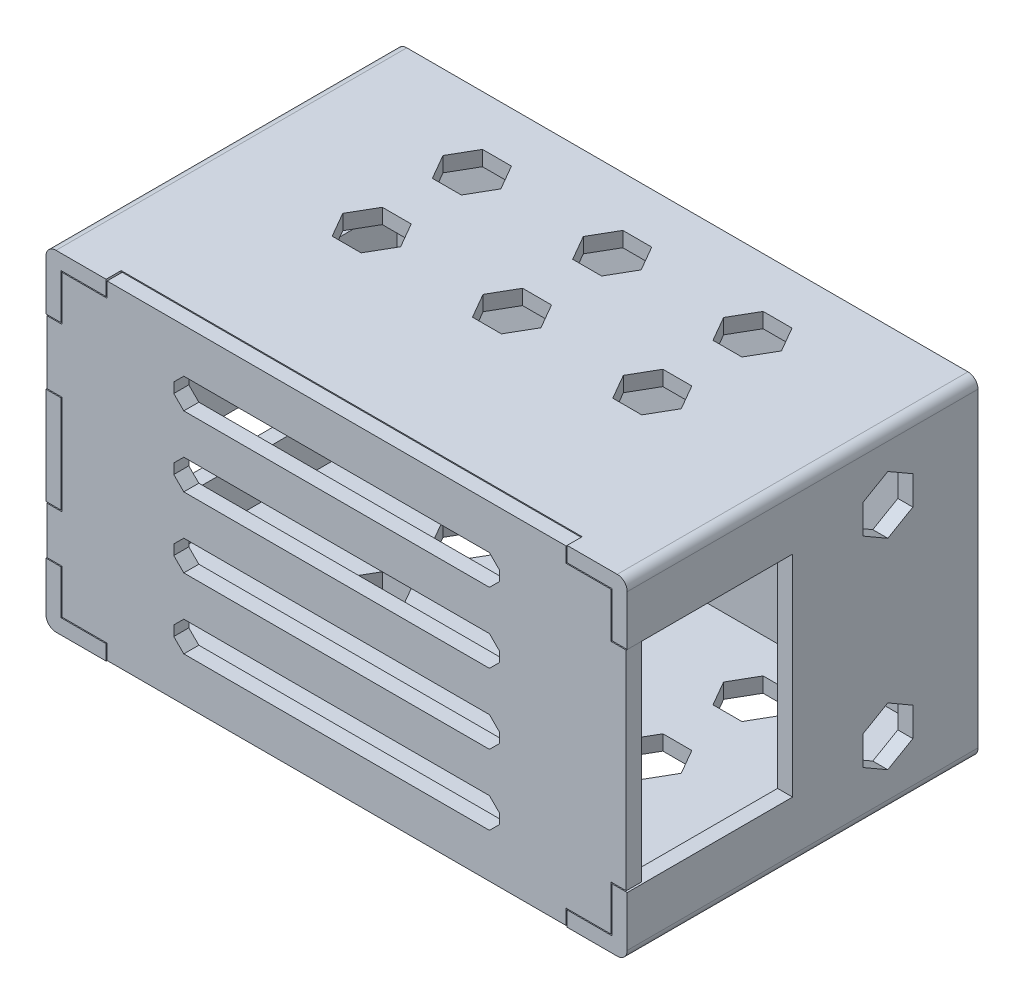
from build123d import *

# Parameters (mm, degrees)
SKETCH1_W           = 116
SKETCH1_H           = 66
SKETCH1_W_2         = 110
SKETCH1_H_2         = 60
BOSS_EXTRUDE1_DEPTH = 70
SKETCH1_2_W         = 110
SKETCH1_2_H         = 60
BOSS_EXTRUDE2_DEPTH = 3
CUT_EXTRUDE1_REACH  = 118
SKETCH2_W           = 65
SKETCH2_H           = 9.8
SKETCH2_H_2         = 13
CUT_EXTRUDE2_DEPTH  = 67
CUT_EXTRUDE3_REACH  = 118
SKETCH5_W           = 92
SKETCH5_H           = 3
SKETCH5_W_2         = 3
SKETCH5_H_2         = 42
CUT_EXTRUDE4_DEPTH  = 3
SKETCH6_W           = 2.8
SKETCH6_H           = 41.6
BOSS_EXTRUDE3_DEPTH = 3
SKETCH7_W           = 65
SKETCH7_H           = 6
CUT_EXTRUDE5_DEPTH  = 3
SKETCH8_W           = 3
SKETCH8_H           = 42
CUT_EXTRUDE6_DEPTH  = 30
CHAMFER1_SIZE       = 2
FILLET1_R           = 2


with BuildPart() as part:
    # Sketch1 → Boss-Extrude1 (new body)
    with BuildSketch(Plane.XY):
        Rectangle(SKETCH1_W, SKETCH1_H)
        Rectangle(SKETCH1_W_2, SKETCH1_H_2, mode=Mode.SUBTRACT)
    extrude(amount=BOSS_EXTRUDE1_DEPTH)

    # Sketch1_2 → Boss-Extrude2 (add)
    with BuildSketch(Plane.XY):
        Rectangle(SKETCH1_2_W, SKETCH1_2_H)
    extrude(amount=BOSS_EXTRUDE2_DEPTH)

    # Sketch2 → Cut-Extrude1 (cut, up to next)
    with BuildSketch(Plane.ZY.offset(58), mode=Mode.PRIVATE) as cut_extrude1_sk1:
        with Locations((37.5, -16.3)):
            Rectangle(SKETCH2_W, SKETCH2_H)
    cut_extrude1_tool1 = extrude(cut_extrude1_sk1.sketch, amount=-CUT_EXTRUDE1_REACH, mode=Mode.PRIVATE) & part.part
    add(cut_extrude1_tool1.solids().sort_by_distance((-58, -16.3, 37.5))[0], mode=Mode.SUBTRACT)
    # Sketch2 → Cut-Extrude1 (cut, up to next)
    with BuildSketch(Plane.ZY.offset(58), mode=Mode.PRIVATE) as cut_extrude1_sk2:
        with Locations((37.5, 14.5)):
            Rectangle(SKETCH2_W, SKETCH2_H_2)
    cut_extrude1_tool2 = extrude(cut_extrude1_sk2.sketch, amount=-CUT_EXTRUDE1_REACH, mode=Mode.PRIVATE) & part.part
    add(cut_extrude1_tool2.solids().sort_by_distance((-58, 14.5, 37.5))[0], mode=Mode.SUBTRACT)

    # Sketch3 → Cut-Extrude2 (cut, through all)
    with BuildSketch(Plane.XZ.offset(33)):
        Polygon((-25.113248654, 40), (-30.886751346, 40), (-33.773502692, 35), (-30.886751346, 30), (-25.113248654, 30), (-22.226497308, 35), align=None)
        Polygon((2.886751346, 40), (-2.886751346, 40), (-5.773502692, 35), (-2.886751346, 30), (2.886751346, 30), (5.773502692, 35), align=None)
        Polygon((30.886751346, 40), (25.113248654, 40), (22.226497308, 35), (25.113248654, 30), (30.886751346, 30), (33.773502692, 35), align=None)
        Polygon((30.886751346, 20), (25.113248654, 20), (22.226497308, 15), (25.113248654, 10), (30.886751346, 10), (33.773502692, 15), align=None)
        Polygon((2.886751346, 20), (-2.886751346, 20), (-5.773502692, 15), (-2.886751346, 10), (2.886751346, 10), (5.773502692, 15), align=None)
        Polygon((-25.113248654, 20), (-30.886751346, 20), (-33.773502692, 15), (-30.886751346, 10), (-25.113248654, 10), (-22.226497308, 15), align=None)
    extrude(amount=-CUT_EXTRUDE2_DEPTH, mode=Mode.SUBTRACT)

    # Sketch4 → Cut-Extrude3 (cut, up to next)
    with BuildSketch(Plane(origin=(58, 0, 0), x_dir=(0, 0, -1), z_dir=(1, 0, 0)), mode=Mode.PRIVATE) as cut_extrude3_sk1:
        Polygon((-18, 25.773502692), (-23, 22.886751346), (-23, 17.113248654), (-18, 14.226497308), (-13, 17.113248654), (-13, 22.886751346), align=None)
    cut_extrude3_tool1 = extrude(cut_extrude3_sk1.sketch, amount=-CUT_EXTRUDE3_REACH, mode=Mode.PRIVATE) & part.part
    add(cut_extrude3_tool1.solids().sort_by_distance((58, 20, 18))[0], mode=Mode.SUBTRACT)
    # Sketch4 → Cut-Extrude3 (cut, up to next)
    with BuildSketch(Plane(origin=(58, 0, 0), x_dir=(0, 0, -1), z_dir=(1, 0, 0)), mode=Mode.PRIVATE) as cut_extrude3_sk2:
        Polygon((-18, -14.226497308), (-23, -17.113248654), (-23, -22.886751346), (-18, -25.773502692), (-13, -22.886751346), (-13, -17.113248654), align=None)
    cut_extrude3_tool2 = extrude(cut_extrude3_sk2.sketch, amount=-CUT_EXTRUDE3_REACH, mode=Mode.PRIVATE) & part.part
    add(cut_extrude3_tool2.solids().sort_by_distance((58, -20, 18))[0], mode=Mode.SUBTRACT)

    # Sketch5 → Cut-Extrude4 (cut)
    with BuildSketch(Plane.XY.offset(70)):
        with Locations((0, 31.5)):
            Rectangle(SKETCH5_W, SKETCH5_H)
        with Locations((0, -31.5)):
            Rectangle(SKETCH5_W, SKETCH5_H)
        with Locations((56.5, 0)):
            Rectangle(SKETCH5_W_2, SKETCH5_H_2)
    extrude(amount=-CUT_EXTRUDE4_DEPTH, mode=Mode.SUBTRACT)

    # Sketch8 → Cut-Extrude6 (cut)
    with BuildSketch(Plane.XY.offset(67)):
        with Locations((56.5, 0)):
            Rectangle(SKETCH8_W, SKETCH8_H)
    extrude(amount=-CUT_EXTRUDE6_DEPTH, mode=Mode.SUBTRACT)

    # Fillet1
    fillet1_edges = [part.edges().sort_by_distance(p)[0] for p in [
        (-58, -33, 35),
        (-58, 33, 35),
        (58, 33, 35),
        (58, -33, 35),
    ]]
    fillet(fillet1_edges, radius=FILLET1_R)


with BuildPart() as body_2:
    # Sketch6 → Boss-Extrude3 (new body)
    with BuildSketch(Plane.XY.offset(67)):
        Polygon((55, -20.8), (55, 20.8), (54.8, 20.8), (54.8, 29.8), (45.8, 29.8), (45.8, 32.8), (-45.8, 32.8), (-45.8, 29.8), (-54.8, 29.8), (-54.8, 20.8), (-57.8, 20.8), (-57.8, 8.2), (-54.8, 8.2), (-54.8, -11.6), (-57.8, -11.6), (-57.8, -21), (-54.8, -21), (-54.8, -29.8), (-45.8, -29.8), (-45.8, -32.8), (45.8, -32.8), (45.8, -29.8), (54.8, -29.8), (54.8, -20.8), align=None)
        with Locations((56.4, 0)):
            Rectangle(SKETCH6_W, SKETCH6_H)
    extrude(amount=BOSS_EXTRUDE3_DEPTH)

    # Sketch7 → Cut-Extrude5 (cut)
    with BuildSketch(Plane.XY.offset(70)):
        with Locations((0, 21)):
            Rectangle(SKETCH7_W, SKETCH7_H)
        with Locations((0, 7)):
            Rectangle(SKETCH7_W, SKETCH7_H)
        with Locations((0, -7)):
            Rectangle(SKETCH7_W, SKETCH7_H)
        with Locations((0, -21)):
            Rectangle(SKETCH7_W, SKETCH7_H)
    extrude(amount=-CUT_EXTRUDE5_DEPTH, mode=Mode.SUBTRACT)

    # Chamfer1
    chamfer1_edges = [body_2.edges().sort_by_distance(p)[0] for p in [
        (-32.5, -10, 68.5),
        (-32.5, -4, 68.5),
        (32.5, -4, 68.5),
        (32.5, -10, 68.5),
        (-32.5, -24, 68.5),
        (-32.5, -18, 68.5),
        (32.5, -18, 68.5),
        (32.5, -24, 68.5),
        (-32.5, 18, 68.5),
        (-32.5, 24, 68.5),
        (32.5, 24, 68.5),
        (32.5, 18, 68.5),
        (-32.5, 4, 68.5),
        (-32.5, 10, 68.5),
        (32.5, 10, 68.5),
        (32.5, 4, 68.5),
    ]]
    chamfer(chamfer1_edges, length=CHAMFER1_SIZE)


solid = Compound([part.part, body_2.part])
